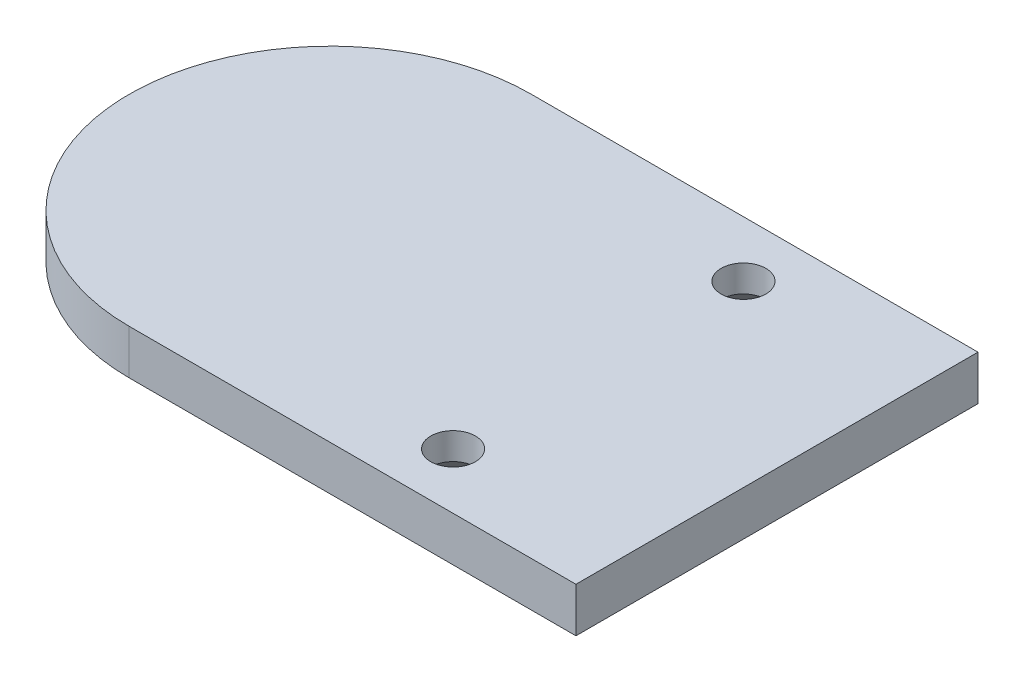
from build123d import *

# Parameters (mm, degrees)
BOSS_EXTRUDE1_DEPTH     = 5
SKETCH2_R               = 2.5
CUT_EXTRUDE1_DEPTH      = 6
CUT_EXTRUDE1_DEPTH_BACK = 1
CHAMFER1_SIZE           = 2


with BuildPart() as part:
    # Sketch1 → Boss-Extrude1 (new body)
    with BuildSketch(Plane(origin=(0, 0, 0), x_dir=(1, 0, 0), z_dir=(0, 1, 0))):
        with BuildLine():
            Line((0, 22.5), (50, 22.5))
            Line((50, 22.5), (50, -22.5))
            Line((50, -22.5), (0, -22.5))
            ThreePointArc((0, -22.5), (-22.5, 0), (0, 22.5))
        make_face()
    extrude(amount=BOSS_EXTRUDE1_DEPTH)

    # Sketch2 → Cut-Extrude1 (cut, two sides)
    with BuildSketch(Plane(origin=(0, 0, 0), x_dir=(1, 0, 0), z_dir=(0, 1, 0))) as cut_extrude1_sk:
        with Locations((30, 16.25)):
            Circle(SKETCH2_R)
        with Locations((30, -16.25)):
            Circle(SKETCH2_R)
    extrude(amount=CUT_EXTRUDE1_DEPTH, mode=Mode.SUBTRACT)
    extrude(cut_extrude1_sk.sketch, amount=-CUT_EXTRUDE1_DEPTH_BACK, mode=Mode.SUBTRACT)

    # Chamfer1
    chamfer1_edges = [part.edges().sort_by_distance(p)[0] for p in [
        (27.5, 0, -16.25),
        (27.5, 0, 16.25),
    ]]
    chamfer(chamfer1_edges, length=CHAMFER1_SIZE)


solid = part.part
